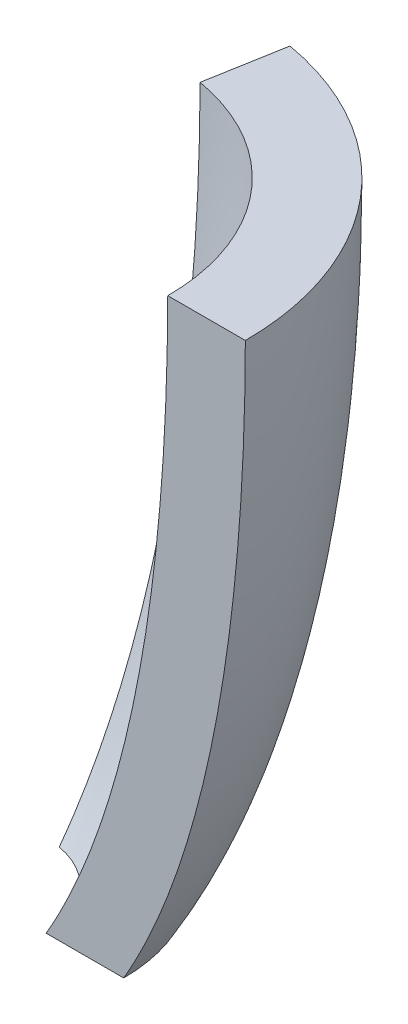
from build123d import *

# Parameters (mm, degrees)
REVOLVE1_ANGLE = 80


with BuildPart() as part:
    # Sketch1 → Revolve1 (revolve)
    with BuildSketch(Plane.XY):
        with BuildLine():
            add(Edge.make_bspline(
                [(36.3, 0), (36.23012255, -33.295965617), (31.135531418, -60.923236963), (20.622193476, -79.012490903)],
                knots=[0, 0, 0, 0, 1, 1, 1, 1], degree=3))
            Line((20.622193476, -79.012490903), (10.622193476, -79.012490903))
            add(Edge.make_bspline(
                [(26.3, 0), (26.23012255, -33.295965617), (21.135531418, -60.923236963), (10.622193476, -79.012490903)],
                knots=[0, 0, 0, 0, 1, 1, 1, 1], degree=3))
            Line((26.3, 0), (36.3, 0))
        make_face()
    revolve(axis=Axis((0, 0, 0), (0, 1, 0)), revolution_arc=REVOLVE1_ANGLE)


solid = part.part
